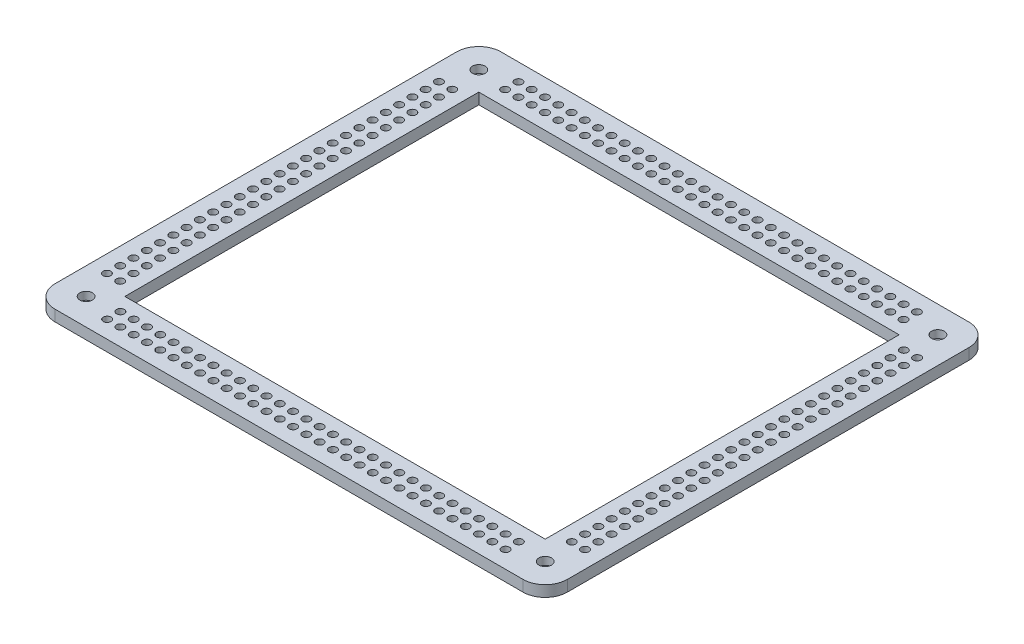
from build123d import *

# Parameters (mm, degrees)
SKETCH1_W               = 231.4
SKETCH1_H               = 201.4
SKETCH1_W_2             = 189.9
SKETCH1_H_2             = 159.9
BOSS_EXTRUDE1_DEPTH     = 5
FILLET1_R               = 10
SKETCH2_R               = 5.85
BOSS_EXTRUDE2_DEPTH     = 2.5
SKETCH3_R               = 1.55
CUT_EXTRUDE1_DEPTH      = 7.5
SKETCH4_R               = 2.85
CUT_EXTRUDE2_DEPTH      = 3.5
MIRROR4_COPY_1_SKETCH_R = 5.85
MIRROR4_COPY_1_DEPTH    = 2.5
MIRROR4_COPY_2_SKETCH_R = 1.55
MIRROR4_COPY_2_DEPTH    = 7.5
MIRROR4_COPY_3_SKETCH_R = 2.85
MIRROR4_COPY_3_DEPTH    = 3.5
SKETCH5_R               = 1.75
CUT_EXTRUDE3_DEPTH      = 10
SKETCH6_R               = 1.75
CUT_EXTRUDE4_DEPTH      = 10


with BuildPart() as part:
    # Sketch1 → Boss-Extrude1 (new body)
    with BuildSketch(Plane(origin=(0, 0, 0), x_dir=(1, 0, 0), z_dir=(0, 1, 0))):
        Rectangle(SKETCH1_W, SKETCH1_H)
        Rectangle(SKETCH1_W_2, SKETCH1_H_2, mode=Mode.SUBTRACT)
    extrude(amount=BOSS_EXTRUDE1_DEPTH)

    # Fillet1
    fillet1_edges = [part.edges().sort_by_distance(p)[0] for p in [
        (-115.7, 2.5, -100.7),
        (115.7, 2.5, -100.7),
        (115.7, 2.5, 100.7),
        (-115.7, 2.5, 100.7),
    ]]
    fillet(fillet1_edges, radius=FILLET1_R)

    # Sketch2 → Boss-Extrude2 (add)
    with BuildSketch(Plane.XZ):
        with Locations((-103.7, 88.7)):
            Circle(SKETCH2_R)
    boss_extrude2 = extrude(amount=BOSS_EXTRUDE2_DEPTH)

    # Sketch3 → Cut-Extrude1 (cut)
    with BuildSketch(Plane(origin=(0, 5, 0), x_dir=(1, 0, 0), z_dir=(0, 1, 0))):
        with Locations((-103.7, -88.7)):
            Circle(SKETCH3_R)
    cut_extrude1 = extrude(amount=-CUT_EXTRUDE1_DEPTH, mode=Mode.SUBTRACT)

    # Sketch4 → Cut-Extrude2 (cut)
    with BuildSketch(Plane(origin=(0, 5, 0), x_dir=(1, 0, 0), z_dir=(0, 1, 0))):
        with Locations((-103.7, -88.7)):
            Circle(SKETCH4_R)
    cut_extrude2 = extrude(amount=-CUT_EXTRUDE2_DEPTH, mode=Mode.SUBTRACT)

    # Mirror3: Boss-Extrude2, Cut-Extrude1, Cut-Extrude2 across plane
    add(boss_extrude2.mirror(Plane(origin=(0, 0, 0), x_dir=(0, 0, 1), z_dir=(1, 0, 0))))
    add(cut_extrude1.mirror(Plane(origin=(0, 0, 0), x_dir=(0, 0, 1), z_dir=(1, 0, 0))), mode=Mode.SUBTRACT)
    add(cut_extrude2.mirror(Plane(origin=(0, 0, 0), x_dir=(0, 0, 1), z_dir=(1, 0, 0))), mode=Mode.SUBTRACT)

    # Mirror4: Boss-Extrude2, Cut-Extrude1, Cut-Extrude2 across plane
    add(boss_extrude2.mirror(Plane.XY))
    add(cut_extrude1.mirror(Plane.XY), mode=Mode.SUBTRACT)
    add(cut_extrude2.mirror(Plane.XY), mode=Mode.SUBTRACT)

    # Mirror4 copy 1 sketch → Mirror4 copy 1 (add)
    with BuildSketch(Plane(origin=(0, 0, 0), x_dir=(-1, 0, 0), z_dir=(0, -1, 0))):
        with Locations((-103.7, 88.7)):
            Circle(MIRROR4_COPY_1_SKETCH_R)
    extrude(amount=MIRROR4_COPY_1_DEPTH)

    # Mirror4 copy 2 sketch → Mirror4 copy 2 (cut)
    with BuildSketch(Plane(origin=(0, 5, 0), x_dir=(-1, 0, 0), z_dir=(0, 1, 0))):
        with Locations((-103.7, -88.7)):
            Circle(MIRROR4_COPY_2_SKETCH_R)
    extrude(amount=-MIRROR4_COPY_2_DEPTH, mode=Mode.SUBTRACT)

    # Mirror4 copy 3 sketch → Mirror4 copy 3 (cut)
    with BuildSketch(Plane(origin=(0, 5, 0), x_dir=(-1, 0, 0), z_dir=(0, 1, 0))):
        with Locations((-103.7, -88.7)):
            Circle(MIRROR4_COPY_3_SKETCH_R)
    extrude(amount=-MIRROR4_COPY_3_DEPTH, mode=Mode.SUBTRACT)

    # Sketch5 → Cut-Extrude3 (cut)
    with BuildSketch(Plane(origin=(0, 5, 0), x_dir=(1, 0, 0), z_dir=(0, 1, 0))):
        with Locations((-90, -86.9)):
            Circle(SKETCH5_R)
        with Locations((-90, -92.9)):
            Circle(SKETCH5_R)
        with Locations((-84, -86.9)):
            Circle(SKETCH5_R)
        with Locations((-84, -92.9)):
            Circle(SKETCH5_R)
        with Locations((-78, -86.9)):
            Circle(SKETCH5_R)
        with Locations((-78, -92.9)):
            Circle(SKETCH5_R)
        with Locations((-72, -86.9)):
            Circle(SKETCH5_R)
        with Locations((-72, -92.9)):
            Circle(SKETCH5_R)
        with Locations((-66, -86.9)):
            Circle(SKETCH5_R)
        with Locations((-66, -92.9)):
            Circle(SKETCH5_R)
        with Locations((-60, -86.9)):
            Circle(SKETCH5_R)
        with Locations((-60, -92.9)):
            Circle(SKETCH5_R)
        with Locations((-54, -86.9)):
            Circle(SKETCH5_R)
        with Locations((-54, -92.9)):
            Circle(SKETCH5_R)
        with Locations((-48, -86.9)):
            Circle(SKETCH5_R)
        with Locations((-48, -92.9)):
            Circle(SKETCH5_R)
        with Locations((-42, -86.9)):
            Circle(SKETCH5_R)
        with Locations((-42, -92.9)):
            Circle(SKETCH5_R)
        with Locations((-36, -86.9)):
            Circle(SKETCH5_R)
        with Locations((-36, -92.9)):
            Circle(SKETCH5_R)
        with Locations((-30, -86.9)):
            Circle(SKETCH5_R)
        with Locations((-30, -92.9)):
            Circle(SKETCH5_R)
        with Locations((-24, -86.9)):
            Circle(SKETCH5_R)
        with Locations((-24, -92.9)):
            Circle(SKETCH5_R)
        with Locations((-18, -86.9)):
            Circle(SKETCH5_R)
        with Locations((-18, -92.9)):
            Circle(SKETCH5_R)
        with Locations((-12, -86.9)):
            Circle(SKETCH5_R)
        with Locations((-12, -92.9)):
            Circle(SKETCH5_R)
        with Locations((-6, -86.9)):
            Circle(SKETCH5_R)
        with Locations((-6, -92.9)):
            Circle(SKETCH5_R)
        with Locations((0, -86.9)):
            Circle(SKETCH5_R)
        with Locations((0, -92.9)):
            Circle(SKETCH5_R)
        with Locations((6, -86.9)):
            Circle(SKETCH5_R)
        with Locations((6, -92.9)):
            Circle(SKETCH5_R)
        with Locations((12, -86.9)):
            Circle(SKETCH5_R)
        with Locations((12, -92.9)):
            Circle(SKETCH5_R)
        with Locations((18, -86.9)):
            Circle(SKETCH5_R)
        with Locations((18, -92.9)):
            Circle(SKETCH5_R)
        with Locations((24, -86.9)):
            Circle(SKETCH5_R)
        with Locations((24, -92.9)):
            Circle(SKETCH5_R)
        with Locations((30, -86.9)):
            Circle(SKETCH5_R)
        with Locations((30, -92.9)):
            Circle(SKETCH5_R)
        with Locations((36, -86.9)):
            Circle(SKETCH5_R)
        with Locations((36, -92.9)):
            Circle(SKETCH5_R)
        with Locations((42, -86.9)):
            Circle(SKETCH5_R)
        with Locations((42, -92.9)):
            Circle(SKETCH5_R)
        with Locations((48, -86.9)):
            Circle(SKETCH5_R)
        with Locations((48, -92.9)):
            Circle(SKETCH5_R)
        with Locations((54, -86.9)):
            Circle(SKETCH5_R)
        with Locations((54, -92.9)):
            Circle(SKETCH5_R)
        with Locations((60, -86.9)):
            Circle(SKETCH5_R)
        with Locations((60, -92.9)):
            Circle(SKETCH5_R)
        with Locations((66, -86.9)):
            Circle(SKETCH5_R)
        with Locations((66, -92.9)):
            Circle(SKETCH5_R)
        with Locations((72, -86.9)):
            Circle(SKETCH5_R)
        with Locations((72, -92.9)):
            Circle(SKETCH5_R)
        with Locations((78, -86.9)):
            Circle(SKETCH5_R)
        with Locations((78, -92.9)):
            Circle(SKETCH5_R)
        with Locations((84, -86.9)):
            Circle(SKETCH5_R)
        with Locations((84, -92.9)):
            Circle(SKETCH5_R)
        with Locations((90, -86.9)):
            Circle(SKETCH5_R)
        with Locations((90, -92.9)):
            Circle(SKETCH5_R)
    cut_extrude3 = extrude(amount=-CUT_EXTRUDE3_DEPTH, mode=Mode.SUBTRACT)

    # Sketch6 → Cut-Extrude4 (cut)
    with BuildSketch(Plane(origin=(0, 5, 0), x_dir=(1, 0, 0), z_dir=(0, 1, 0))):
        with Locations((-102, -75)):
            Circle(SKETCH6_R)
        with Locations((-108, -75)):
            Circle(SKETCH6_R)
        with Locations((-102, -69)):
            Circle(SKETCH6_R)
        with Locations((-108, -69)):
            Circle(SKETCH6_R)
        with Locations((-102, -63)):
            Circle(SKETCH6_R)
        with Locations((-108, -63)):
            Circle(SKETCH6_R)
        with Locations((-102, -57)):
            Circle(SKETCH6_R)
        with Locations((-108, -57)):
            Circle(SKETCH6_R)
        with Locations((-102, -51)):
            Circle(SKETCH6_R)
        with Locations((-108, -51)):
            Circle(SKETCH6_R)
        with Locations((-102, -45)):
            Circle(SKETCH6_R)
        with Locations((-108, -45)):
            Circle(SKETCH6_R)
        with Locations((-102, -39)):
            Circle(SKETCH6_R)
        with Locations((-108, -39)):
            Circle(SKETCH6_R)
        with Locations((-102, -33)):
            Circle(SKETCH6_R)
        with Locations((-108, -33)):
            Circle(SKETCH6_R)
        with Locations((-102, -27)):
            Circle(SKETCH6_R)
        with Locations((-108, -27)):
            Circle(SKETCH6_R)
        with Locations((-102, -21)):
            Circle(SKETCH6_R)
        with Locations((-108, -21)):
            Circle(SKETCH6_R)
        with Locations((-102, -15)):
            Circle(SKETCH6_R)
        with Locations((-108, -15)):
            Circle(SKETCH6_R)
        with Locations((-102, -9)):
            Circle(SKETCH6_R)
        with Locations((-108, -9)):
            Circle(SKETCH6_R)
        with Locations((-102, -3)):
            Circle(SKETCH6_R)
        with Locations((-108, -3)):
            Circle(SKETCH6_R)
        with Locations((-102, 3)):
            Circle(SKETCH6_R)
        with Locations((-108, 3)):
            Circle(SKETCH6_R)
        with Locations((-102, 9)):
            Circle(SKETCH6_R)
        with Locations((-108, 9)):
            Circle(SKETCH6_R)
        with Locations((-102, 15)):
            Circle(SKETCH6_R)
        with Locations((-108, 15)):
            Circle(SKETCH6_R)
        with Locations((-102, 21)):
            Circle(SKETCH6_R)
        with Locations((-108, 21)):
            Circle(SKETCH6_R)
        with Locations((-102, 27)):
            Circle(SKETCH6_R)
        with Locations((-108, 27)):
            Circle(SKETCH6_R)
        with Locations((-102, 33)):
            Circle(SKETCH6_R)
        with Locations((-108, 33)):
            Circle(SKETCH6_R)
        with Locations((-102, 39)):
            Circle(SKETCH6_R)
        with Locations((-108, 39)):
            Circle(SKETCH6_R)
        with Locations((-102, 45)):
            Circle(SKETCH6_R)
        with Locations((-108, 45)):
            Circle(SKETCH6_R)
        with Locations((-102, 51)):
            Circle(SKETCH6_R)
        with Locations((-108, 51)):
            Circle(SKETCH6_R)
        with Locations((-102, 57)):
            Circle(SKETCH6_R)
        with Locations((-108, 57)):
            Circle(SKETCH6_R)
        with Locations((-102, 63)):
            Circle(SKETCH6_R)
        with Locations((-108, 63)):
            Circle(SKETCH6_R)
        with Locations((-102, 69)):
            Circle(SKETCH6_R)
        with Locations((-108, 69)):
            Circle(SKETCH6_R)
        with Locations((-102, 75)):
            Circle(SKETCH6_R)
        with Locations((-108, 75)):
            Circle(SKETCH6_R)
    cut_extrude4 = extrude(amount=-CUT_EXTRUDE4_DEPTH, mode=Mode.SUBTRACT)

    # Mirror5: Cut-Extrude3 across plane
    add(cut_extrude3.mirror(Plane.XY), mode=Mode.SUBTRACT)

    # Mirror6: Cut-Extrude4 across plane
    add(cut_extrude4.mirror(Plane(origin=(0, 0, 0), x_dir=(0, 0, 1), z_dir=(1, 0, 0))), mode=Mode.SUBTRACT)


solid = part.part
